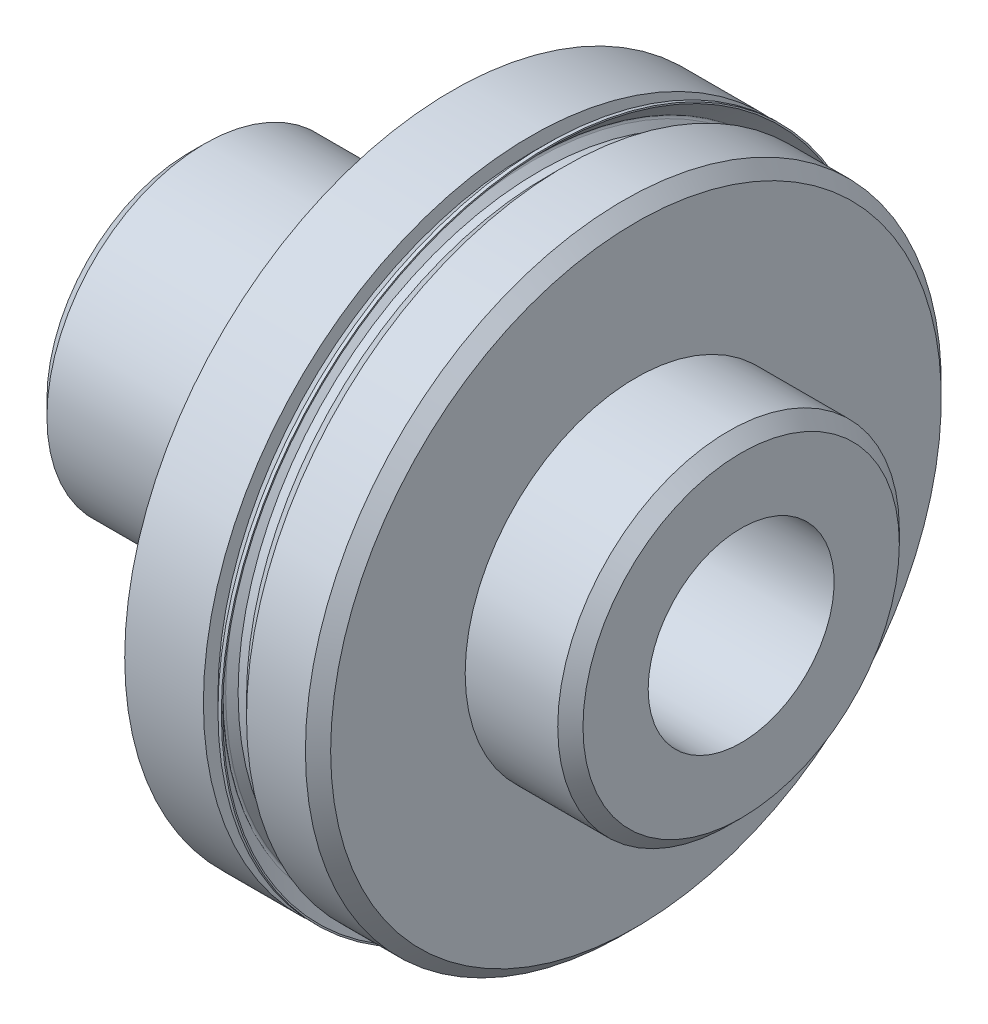
from build123d import *

# Parameters (mm, degrees)
HOLE1_D           = 11.2268
HOLE1_CSINK_D     = 12.7508
HOLE1_CSINK_ANGLE = 90


with BuildPart() as part:
    # Sketch1 → Revolve1 (revolve)
    with BuildSketch(Plane.XY):
        with BuildLine():
            Line((0, 0), (0, 8.58901))
            Line((0, 8.58901), (0.93599, 9.525))
            Line((0.93599, 9.525), (9.310047461, 9.525))
            Line((9.310047461, 9.525), (10.262333187, 8.610821042))
            ThreePointArc((10.262333187, 8.610821042), (10.619173954, 8.380210754), (11.0363, 8.29945))
            Line((11.0363, 8.29945), (12.3698, 8.29945))
            ThreePointArc((12.3698, 8.29945), (13.160062539, 8.626787461), (13.4874, 9.41705))
            Line((13.4874, 9.41705), (13.4874, 9.49325))
            Line((13.4874, 9.49325), (15.875, 9.49325))
            Line((15.875, 9.49325), (15.875, 0))
            Line((15.875, 0), (0, 0))
        make_face()
    revolve(axis=Axis((15.875, 0, 0), (-1, 0, 0)))

    # Sketch2 → Revolve2 (revolve)
    with BuildSketch(Plane.XY):
        Polygon((15.875, 0), (15.875, 19.76755), (20.6248, 19.76755), (20.6248, 18.18005), (21.6408, 18.18005), (22.6568, 19.19605), (26.2128, 19.19605), (26.9748, 18.43405), (26.9748, 0), align=None)
    revolve(axis=Axis((26.9748, 0, 0), (-1, 0, 0)))

    # Sketch3 → Revolve3 (revolve)
    with BuildSketch(Plane.XY):
        Polygon((26.9748, 0), (26.9748, 10.3124), (32.5628, 10.3124), (33.3248, 9.5504), (33.3248, 0), align=None)
    revolve(axis=Axis((33.3248, 0, 0), (-1, 0, 0)))

    # Hole1 (through all)
    with Locations(Plane.ZY):
        with Locations((0, 0)):
            CounterSinkHole(HOLE1_D / 2, HOLE1_CSINK_D / 2, counter_sink_angle=HOLE1_CSINK_ANGLE)

    # Sketch6 → Revolve4 (revolve)
    with BuildSketch(Plane.XY):
        with BuildLine():
            Line((20.6248, 17.92605), (21.6408, 17.92605))
            Line((21.6408, 17.92605), (21.6408, 18.18005))
            Line((21.6408, 18.18005), (21.1328, 18.18005))
            Line((21.1328, 18.18005), (20.758182072, 18.554667928))
            ThreePointArc((20.758182072, 18.554667928), (20.720984633, 18.64447049), (20.758182072, 18.734273051))
            Line((20.758182072, 18.734273051), (21.707290825, 19.683381804))
            Line((21.707290825, 19.683381804), (21.707290825, 19.76755))
            Line((21.707290825, 19.76755), (21.504090825, 19.76755))
            Line((21.504090825, 19.76755), (20.6248, 18.888259175))
            Line((20.6248, 18.888259175), (20.6248, 17.92605))
        make_face()
    revolve(axis=Axis((21.6408, 0, 0), (-1, 0, 0)))


solid = part.part
